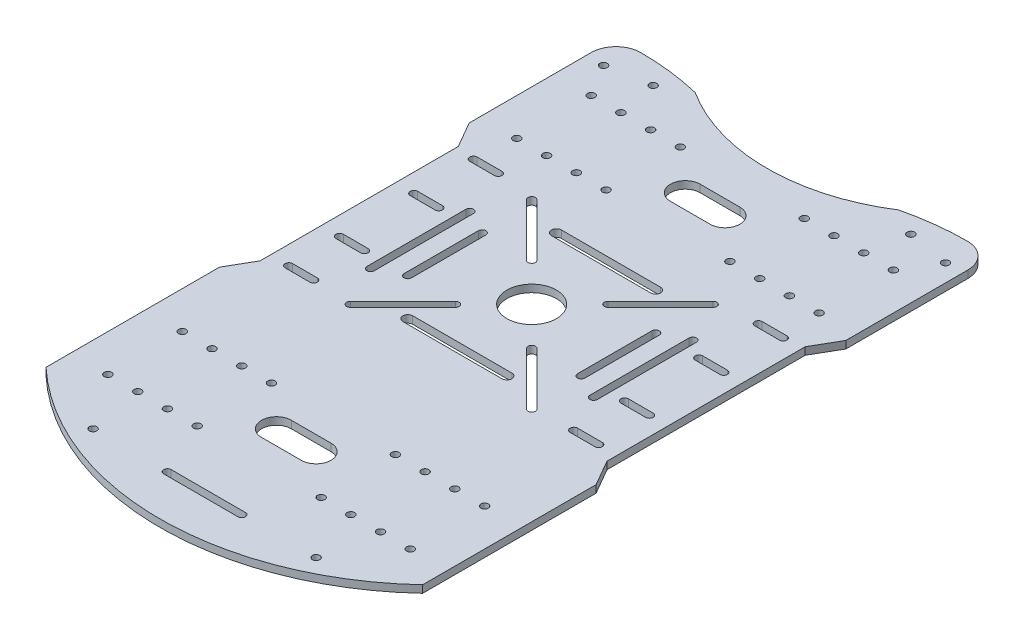
from build123d import *

# Parameters (mm, degrees)
SKETCH2_R           = 1.5
SKETCH2_R_2         = 10
BOSS_EXTRUDE1_DEPTH = 3


with BuildPart() as part:
    # Sketch2 → Boss-Extrude1 (new body)
    with BuildSketch(Plane(origin=(0, 0, 0), x_dir=(1, 0, 0), z_dir=(0, 1, 0))):
        with BuildLine():
            ThreePointArc((-41, 107), (-53.410321688, 109.247319267), (-66, 110))
            ThreePointArc((-66, 110), (-73.071067812, 107.071067812), (-76, 100))
            Line((-76, 100), (-76, 50.784609691))
            Line((-76, 50.784609691), (-70, 40.392304845))
            Line((-70, 40.392304845), (-70, -39.607695155))
            Line((-70, -39.607695155), (-76, -50))
            Line((-76, -50), (-76, -120))
            ThreePointArc((-76, -120), (-40.853396256, -142.228604363), (3.77e-07, -150))
            ThreePointArc((3.77e-07, -150), (40.853396607, -142.228604224), (76, -120))
            Line((76, -120), (76, -50))
            Line((76, -50), (70, -39.607695155))
            Line((70, -39.607695155), (70, 40.392304845))
            Line((70, 40.392304845), (76, 50.784609691))
            Line((76, 50.784609691), (76, 100))
            ThreePointArc((76, 100), (73.071067812, 107.071067812), (66, 110))
            ThreePointArc((66, 110), (53.410321688, 109.247319267), (41, 107))
            ThreePointArc((41, 107), (0, 95), (-41, 107))
        make_face()
        with Locations((-45, -132)):
            Circle(SKETCH2_R, mode=Mode.SUBTRACT)
        with Locations((-61, -110)):
            Circle(SKETCH2_R, mode=Mode.SUBTRACT)
        with Locations((-49, -110)):
            Circle(SKETCH2_R, mode=Mode.SUBTRACT)
        with Locations((-37, -110)):
            Circle(SKETCH2_R, mode=Mode.SUBTRACT)
        with Locations((-25, -110)):
            Circle(SKETCH2_R, mode=Mode.SUBTRACT)
        with BuildLine():
            ThreePointArc((-8, -101), (-14, -95), (-8, -89))
            Line((-8, -89), (8, -89))
            ThreePointArc((8, -89), (14, -95), (8, -101))
            Line((8, -101), (-8, -101))
        make_face(mode=Mode.SUBTRACT)
        with Locations((-61, -80)):
            Circle(SKETCH2_R, mode=Mode.SUBTRACT)
        with Locations((-49, -80)):
            Circle(SKETCH2_R, mode=Mode.SUBTRACT)
        with BuildLine():
            ThreePointArc((-62.5, -37), (-64, -35.5), (-62.5, -34))
            Line((-62.5, -34), (-52.5, -34))
            ThreePointArc((-52.5, -34), (-51, -35.5), (-52.5, -37))
            Line((-52.5, -37), (-62.5, -37))
        make_face(mode=Mode.SUBTRACT)
        with Locations((-37, -80)):
            Circle(SKETCH2_R, mode=Mode.SUBTRACT)
        with Locations((-25, -80)):
            Circle(SKETCH2_R, mode=Mode.SUBTRACT)
        with BuildLine():
            Line((-14.33273811, -16.454058454), (-35.545941546, -37.66726189))
            ThreePointArc((-35.545941546, -37.66726189), (-37.66726189, -37.66726189), (-37.66726189, -35.545941546))
            Line((-37.66726189, -35.545941546), (-16.454058454, -14.33273811))
            ThreePointArc((-16.454058454, -14.33273811), (-14.33273811, -14.33273811), (-14.33273811, -16.454058454))
        make_face(mode=Mode.SUBTRACT)
        with BuildLine():
            Line((20, -32), (-20, -32))
            ThreePointArc((-20, -32), (-22, -30), (-20, -28))
            Line((-20, -28), (20, -28))
            ThreePointArc((20, -28), (22, -30), (20, -32))
        make_face(mode=Mode.SUBTRACT)
        with BuildLine():
            ThreePointArc((-15, -133.5), (-16.5, -132), (-15, -130.5))
            Line((-15, -130.5), (15, -130.5))
            ThreePointArc((15, -130.5), (16.5, -132), (15, -133.5))
            Line((15, -133.5), (-15, -133.5))
        make_face(mode=Mode.SUBTRACT)
        with Locations((25, -110)):
            Circle(SKETCH2_R, mode=Mode.SUBTRACT)
        with Locations((37, -110)):
            Circle(SKETCH2_R, mode=Mode.SUBTRACT)
        with Locations((45, -132)):
            Circle(SKETCH2_R, mode=Mode.SUBTRACT)
        with Locations((49, -110)):
            Circle(SKETCH2_R, mode=Mode.SUBTRACT)
        with Locations((61, -110)):
            Circle(SKETCH2_R, mode=Mode.SUBTRACT)
        with Locations((25, -80)):
            Circle(SKETCH2_R, mode=Mode.SUBTRACT)
        with Locations((37, -80)):
            Circle(SKETCH2_R, mode=Mode.SUBTRACT)
        with BuildLine():
            ThreePointArc((37.66726189, -35.545941546), (37.66726189, -37.66726189), (35.545941546, -37.66726189))
            Line((35.545941546, -37.66726189), (14.33273811, -16.454058454))
            ThreePointArc((14.33273811, -16.454058454), (14.33273811, -14.33273811), (16.454058454, -14.33273811))
            Line((16.454058454, -14.33273811), (37.66726189, -35.545941546))
        make_face(mode=Mode.SUBTRACT)
        with Locations((49, -80)):
            Circle(SKETCH2_R, mode=Mode.SUBTRACT)
        with Locations((61, -80)):
            Circle(SKETCH2_R, mode=Mode.SUBTRACT)
        with BuildLine():
            Line((52.5, -34), (62.5, -34))
            ThreePointArc((62.5, -34), (64, -35.5), (62.5, -37))
            Line((62.5, -37), (52.5, -37))
            ThreePointArc((52.5, -37), (51, -35.5), (52.5, -34))
        make_face(mode=Mode.SUBTRACT)
        with BuildLine():
            Line((-52.5, -16.5), (-62.5, -16.5))
            ThreePointArc((-62.5, -16.5), (-64, -15), (-62.5, -13.5))
            Line((-62.5, -13.5), (-52.5, -13.5))
            ThreePointArc((-52.5, -13.5), (-51, -15), (-52.5, -16.5))
        make_face(mode=Mode.SUBTRACT)
        with BuildLine():
            ThreePointArc((-43.5, -20), (-45, -21.5), (-46.5, -20))
            Line((-46.5, -20), (-46.5, 20))
            ThreePointArc((-46.5, 20), (-45, 21.5), (-43.5, 20))
            Line((-43.5, 20), (-43.5, -20))
        make_face(mode=Mode.SUBTRACT)
        with BuildLine():
            ThreePointArc((-62.5, 13.5), (-64, 15), (-62.5, 16.5))
            Line((-62.5, 16.5), (-52.5, 16.5))
            ThreePointArc((-52.5, 16.5), (-51, 15), (-52.5, 13.5))
            Line((-52.5, 13.5), (-62.5, 13.5))
        make_face(mode=Mode.SUBTRACT)
        with BuildLine():
            ThreePointArc((-62.5, 37.5), (-64, 39), (-62.5, 40.5))
            Line((-62.5, 40.5), (-52.5, 40.5))
            ThreePointArc((-52.5, 40.5), (-51, 39), (-52.5, 37.5))
            Line((-52.5, 37.5), (-62.5, 37.5))
        make_face(mode=Mode.SUBTRACT)
        with BuildLine():
            ThreePointArc((-33.5, -15), (-35, -16.5), (-36.5, -15))
            Line((-36.5, -15), (-36.5, 15))
            ThreePointArc((-36.5, 15), (-35, 16.5), (-33.5, 15))
            Line((-33.5, 15), (-33.5, -15))
        make_face(mode=Mode.SUBTRACT)
        with BuildLine():
            ThreePointArc((-37.66726189, 35.545941546), (-37.66726189, 37.66726189), (-35.545941546, 37.66726189))
            Line((-35.545941546, 37.66726189), (-14.33273811, 16.454058454))
            ThreePointArc((-14.33273811, 16.454058454), (-14.33273811, 14.33273811), (-16.454058454, 14.33273811))
            Line((-16.454058454, 14.33273811), (-37.66726189, 35.545941546))
        make_face(mode=Mode.SUBTRACT)
        with BuildLine():
            ThreePointArc((-20, 28), (-22, 30), (-20, 32))
            Line((-20, 32), (20, 32))
            ThreePointArc((20, 32), (22, 30), (20, 28))
            Line((20, 28), (-20, 28))
        make_face(mode=Mode.SUBTRACT)
        with Locations((-61, 55)):
            Circle(SKETCH2_R, mode=Mode.SUBTRACT)
        with Locations((-49, 55)):
            Circle(SKETCH2_R, mode=Mode.SUBTRACT)
        with Locations((-61, 85)):
            Circle(SKETCH2_R, mode=Mode.SUBTRACT)
        with Locations((-69, 98)):
            Circle(SKETCH2_R, mode=Mode.SUBTRACT)
        with Locations((-49, 85)):
            Circle(SKETCH2_R, mode=Mode.SUBTRACT)
        with Locations((-52, 101)):
            Circle(SKETCH2_R, mode=Mode.SUBTRACT)
        with Locations((-37, 55)):
            Circle(SKETCH2_R, mode=Mode.SUBTRACT)
        with Locations((-25, 55)):
            Circle(SKETCH2_R, mode=Mode.SUBTRACT)
        with BuildLine():
            ThreePointArc((-8, 64), (-14, 70), (-8, 76))
            Line((-8, 76), (8, 76))
            ThreePointArc((8, 76), (14, 70), (8, 64))
            Line((8, 64), (-8, 64))
        make_face(mode=Mode.SUBTRACT)
        with Locations((-37, 85)):
            Circle(SKETCH2_R, mode=Mode.SUBTRACT)
        with Locations((-25, 85)):
            Circle(SKETCH2_R, mode=Mode.SUBTRACT)
        Circle(SKETCH2_R_2, mode=Mode.SUBTRACT)
        with BuildLine():
            Line((36.5, 15), (36.5, -15))
            ThreePointArc((36.5, -15), (35, -16.5), (33.5, -15))
            Line((33.5, -15), (33.5, 15))
            ThreePointArc((33.5, 15), (35, 16.5), (36.5, 15))
        make_face(mode=Mode.SUBTRACT)
        with BuildLine():
            Line((14.33273811, 16.454058454), (35.545941546, 37.66726189))
            ThreePointArc((35.545941546, 37.66726189), (37.66726189, 37.66726189), (37.66726189, 35.545941546))
            Line((37.66726189, 35.545941546), (16.454058454, 14.33273811))
            ThreePointArc((16.454058454, 14.33273811), (14.33273811, 14.33273811), (14.33273811, 16.454058454))
        make_face(mode=Mode.SUBTRACT)
        with BuildLine():
            Line((46.5, 20), (46.5, -20))
            ThreePointArc((46.5, -20), (45, -21.5), (43.5, -20))
            Line((43.5, -20), (43.5, 20))
            ThreePointArc((43.5, 20), (45, 21.5), (46.5, 20))
        make_face(mode=Mode.SUBTRACT)
        with BuildLine():
            ThreePointArc((62.5, -13.5), (64, -15), (62.5, -16.5))
            Line((62.5, -16.5), (52.5, -16.5))
            ThreePointArc((52.5, -16.5), (51, -15), (52.5, -13.5))
            Line((52.5, -13.5), (62.5, -13.5))
        make_face(mode=Mode.SUBTRACT)
        with BuildLine():
            Line((52.5, 16.5), (62.5, 16.5))
            ThreePointArc((62.5, 16.5), (64, 15), (62.5, 13.5))
            Line((62.5, 13.5), (52.5, 13.5))
            ThreePointArc((52.5, 13.5), (51, 15), (52.5, 16.5))
        make_face(mode=Mode.SUBTRACT)
        with BuildLine():
            Line((52.5, 40.5), (62.5, 40.5))
            ThreePointArc((62.5, 40.5), (64, 39), (62.5, 37.5))
            Line((62.5, 37.5), (52.5, 37.5))
            ThreePointArc((52.5, 37.5), (51, 39), (52.5, 40.5))
        make_face(mode=Mode.SUBTRACT)
        with Locations((25, 55)):
            Circle(SKETCH2_R, mode=Mode.SUBTRACT)
        with Locations((37, 55)):
            Circle(SKETCH2_R, mode=Mode.SUBTRACT)
        with Locations((25, 85)):
            Circle(SKETCH2_R, mode=Mode.SUBTRACT)
        with Locations((37, 85)):
            Circle(SKETCH2_R, mode=Mode.SUBTRACT)
        with Locations((49, 55)):
            Circle(SKETCH2_R, mode=Mode.SUBTRACT)
        with Locations((61, 55)):
            Circle(SKETCH2_R, mode=Mode.SUBTRACT)
        with Locations((49, 85)):
            Circle(SKETCH2_R, mode=Mode.SUBTRACT)
        with Locations((52, 101)):
            Circle(SKETCH2_R, mode=Mode.SUBTRACT)
        with Locations((61, 85)):
            Circle(SKETCH2_R, mode=Mode.SUBTRACT)
        with Locations((69, 98)):
            Circle(SKETCH2_R, mode=Mode.SUBTRACT)
    extrude(amount=BOSS_EXTRUDE1_DEPTH)


solid = part.part
